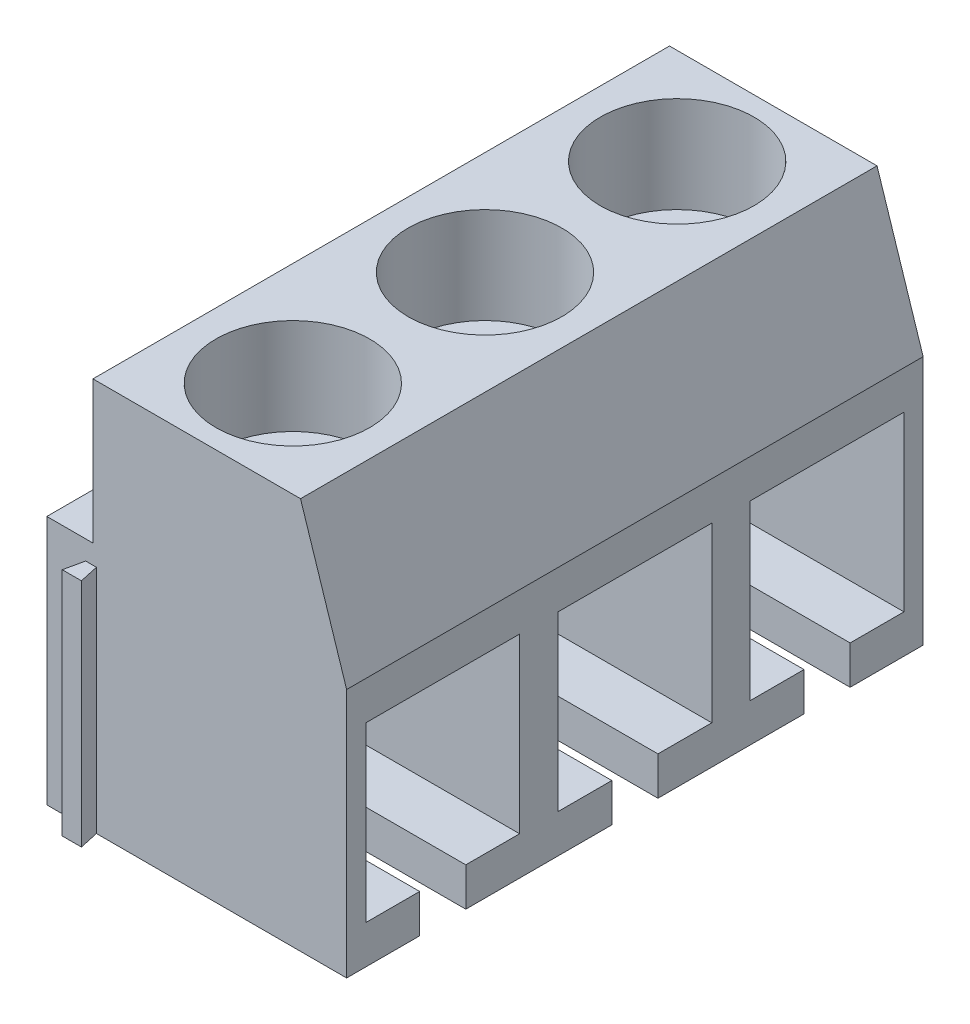
from build123d import *

# Parameters (mm, degrees)
BOSS_EXTRUDE1_DEPTH = 15
SKETCH3_R           = 2
CUT_EXTRUDE2_DEPTH  = 2.5
SKETCH4_R           = 1
CUT_EXTRUDE3_DEPTH  = 3
SKETCH2_W           = 4
SKETCH2_H           = 4.5
CUT_EXTRUDE1_DEPTH  = 6
SKETCH5_W           = 1.2
SKETCH5_H           = 2
CUT_EXTRUDE4_DEPTH  = 5.2
SKETCH6_W           = 0.5
SKETCH6_H           = 6
BOSS_EXTRUDE2_DEPTH = 0.5
SKETCH7_W           = 0.5
SKETCH7_H           = 6
CUT_EXTRUDE5_DEPTH  = 0.5
LPATTERN1_COUNT     = 3
LPATTERN1_PITCH     = 5
CUT_EXTRUDE6_DEPTH  = 10
BOSS_EXTRUDE3_DEPTH = 6


with BuildPart() as part:
    # Sketch1 → Boss-Extrude1 (new body)
    with BuildSketch(Plane.XY):
        Polygon((2.7, 5.1), (-2.7, 5.1), (-2.7, 1.4), (-3.9, 1.4), (-3.9, -5.1), (3.9, -5.1), (3.9, 1.4), align=None)
    extrude(amount=-BOSS_EXTRUDE1_DEPTH)

    # Sketch3 → Cut-Extrude2 (cut)
    with BuildSketch(Plane(origin=(0, 5.1, 0), x_dir=(1, 0, 0), z_dir=(0, 1, 0))):
        with Locations((0, 2.5)):
            Circle(SKETCH3_R)
        with Locations((0, 7.5)):
            Circle(SKETCH3_R)
        with Locations((0, 12.5)):
            Circle(SKETCH3_R)
    extrude(amount=-CUT_EXTRUDE2_DEPTH, mode=Mode.SUBTRACT)

    # Sketch4 → Cut-Extrude3 (cut)
    with BuildSketch(Plane(origin=(0, 2.6, 0), x_dir=(1, 0, 0), z_dir=(0, 1, 0))):
        with Locations((0, 2.5)):
            Circle(SKETCH4_R)
        with Locations((0, 7.5)):
            Circle(SKETCH4_R)
        with Locations((0, 12.5)):
            Circle(SKETCH4_R)
    extrude(amount=-CUT_EXTRUDE3_DEPTH, mode=Mode.SUBTRACT)

    # Sketch2 → Cut-Extrude1 (cut)
    with BuildSketch(Plane(origin=(3.9, 0, 0), x_dir=(0, 0, -1), z_dir=(1, 0, 0))):
        with Locations((2.5, -1.85)):
            Rectangle(SKETCH2_W, SKETCH2_H)
    cut_extrude1 = extrude(amount=-CUT_EXTRUDE1_DEPTH, mode=Mode.SUBTRACT)

    # Sketch5 → Cut-Extrude4 (cut)
    with BuildSketch(Plane(origin=(3.9, 0, 0), x_dir=(0, 0, -1), z_dir=(1, 0, 0))):
        with Locations((2.5, -5.1)):
            Rectangle(SKETCH5_W, SKETCH5_H)
    cut_extrude4 = extrude(amount=-CUT_EXTRUDE4_DEPTH, mode=Mode.SUBTRACT)

    # Sketch6 → Boss-Extrude2 (add)
    with BuildSketch(Plane.XY):
        with Locations((-2.75, -2.1)):
            Rectangle(SKETCH6_W, SKETCH6_H)
    extrude(amount=BOSS_EXTRUDE2_DEPTH)

    # Sketch7 → Cut-Extrude5 (cut)
    with BuildSketch(Plane(origin=(0, 0, -15), x_dir=(-1, 0, 0), z_dir=(0, 0, -1))):
        with Locations((2.75, -2.1)):
            Rectangle(SKETCH7_W, SKETCH7_H)
    extrude(amount=-CUT_EXTRUDE5_DEPTH, mode=Mode.SUBTRACT)

    # LPattern1: Cut-Extrude1, Cut-Extrude4 ×3
    with Locations(*[(0, 0, -i * LPATTERN1_PITCH) for i in range(1, LPATTERN1_COUNT)]):
        add(cut_extrude1, mode=Mode.SUBTRACT)
        add(cut_extrude4, mode=Mode.SUBTRACT)

    # Sketch8 → Cut-Extrude6 (cut)
    with BuildSketch(Plane(origin=(0, 0.9, 0), x_dir=(1, 0, 0), z_dir=(0, 1, 0))):
        Polygon((-3, -0.5), (-2.89, 0), (-3, 0), align=None)
        Polygon((-2.5, -0.5), (-2.61, 0), (-2.5, 0), align=None)
    extrude(amount=-CUT_EXTRUDE6_DEPTH, mode=Mode.SUBTRACT)

    # Sketch9 → Boss-Extrude3 (add)
    with BuildSketch(Plane.XZ.offset(5.1)):
        Polygon((-3, -14.5), (-2.89, -15), (-3, -15), align=None)
        Polygon((-2.5, -14.5), (-2.61, -15), (-2.5, -15), align=None)
    extrude(amount=-BOSS_EXTRUDE3_DEPTH)


solid = part.part
